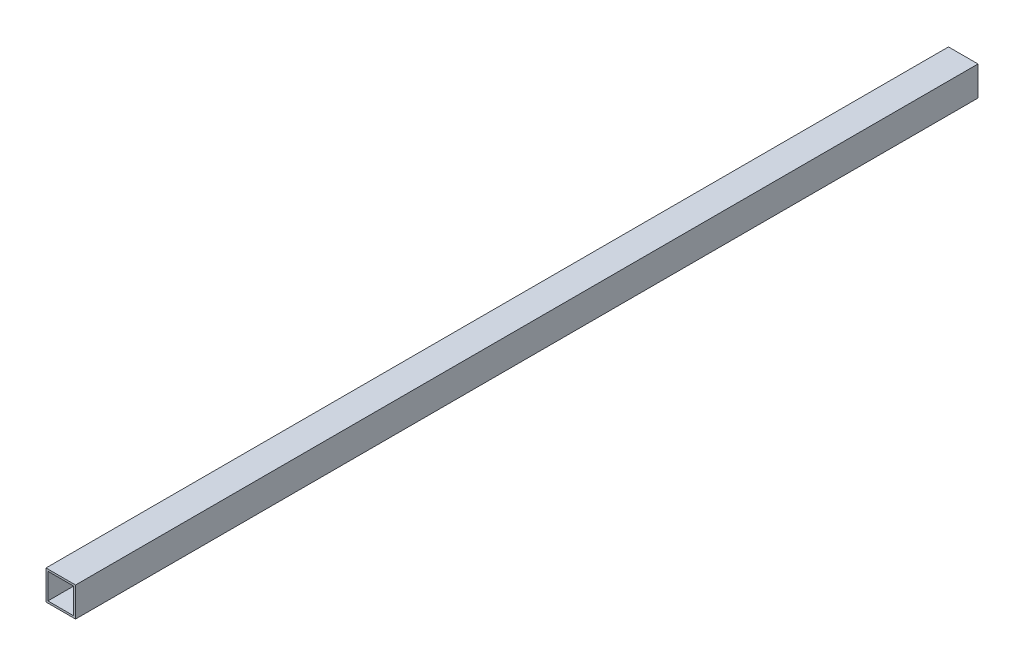
from build123d import *

# Parameters (mm, degrees)
SKETCH1_W                                      = 25.4
SKETCH1_H                                      = 25.4
SKETCH1_W_2                                    = 22.098
SKETCH1_H_2                                    = 22.098
AL_TUBE_SQUARE_AL_TUBE_1_SQR_X_0_065_WAL_DEPTH = 776


with BuildPart() as part:
    # Sketch1 → Al tube square AL TUBE 1 SQR X 0.065 WALL(1) (new body)
    with BuildSketch(Plane(origin=(0, 0, 0), x_dir=(-1, 0, 0), z_dir=(0, 0, -1))):
        Rectangle(SKETCH1_W, SKETCH1_H)
        Rectangle(SKETCH1_W_2, SKETCH1_H_2, mode=Mode.SUBTRACT)
    extrude(amount=AL_TUBE_SQUARE_AL_TUBE_1_SQR_X_0_065_WAL_DEPTH)


solid = part.part
